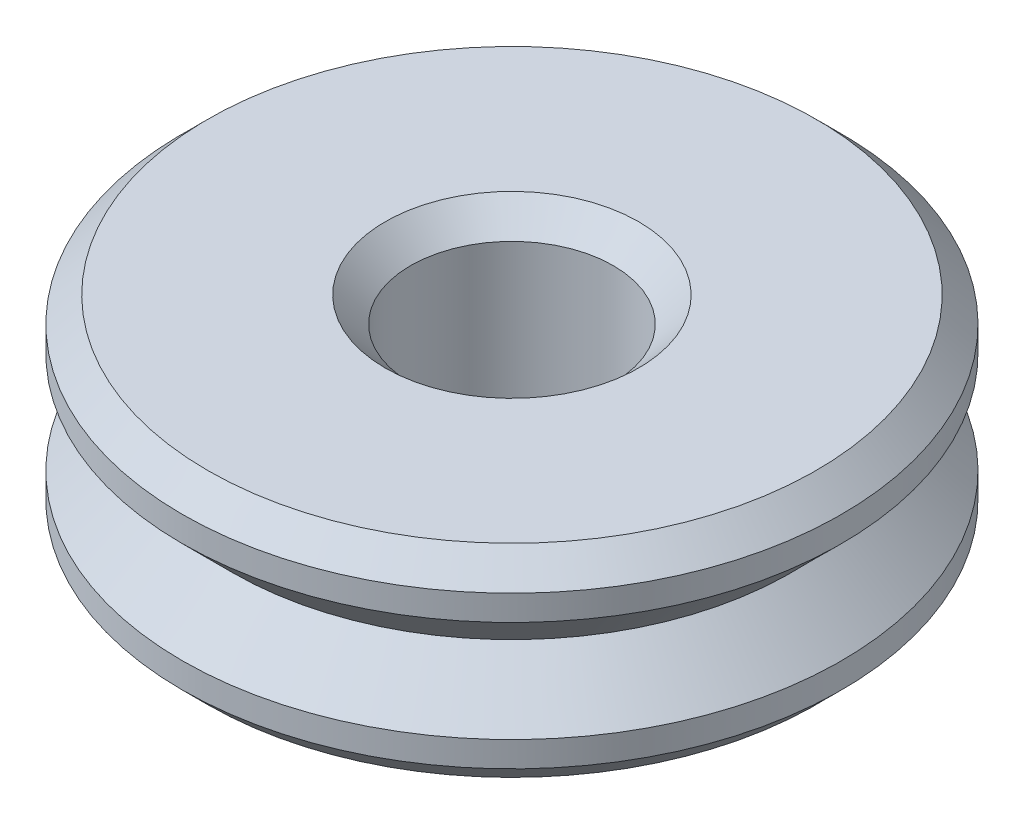
from build123d import *

# Parameters (mm, degrees)
SKETCH1_R           = 6.5
SKETCH1_R_2         = 2
BOSS_EXTRUDE1_DEPTH = 4
CHAMFER1_SIZE       = 0.5


with BuildPart() as part:
    # Sketch1 → Boss-Extrude1 (new body)
    with BuildSketch(Plane(origin=(0, 0, 0), x_dir=(1, 0, 0), z_dir=(0, 1, 0))):
        Circle(SKETCH1_R)
        Circle(SKETCH1_R_2, mode=Mode.SUBTRACT)
    extrude(amount=BOSS_EXTRUDE1_DEPTH)

    # Sketch2 → Cut-Revolve1 (revolve, cut)
    with BuildSketch(Plane(origin=(0, 0, 0), x_dir=(0, 0, -1), z_dir=(1, 0, 0))):
        Polygon((-6.5, 3), (-6.5, 1), (-5.5, 2), align=None)
    revolve(axis=Axis((0, 4, 0), (0, -1, 0)), mode=Mode.SUBTRACT)

    # Chamfer1
    chamfer1_edges = [part.edges().sort_by_distance(p)[0] for p in [
        (-6.5, 0, 0),
        (-6.5, 4, 0),
        (-2, 0, 0),
        (-2, 4, 0),
    ]]
    chamfer(chamfer1_edges, length=CHAMFER1_SIZE)


solid = part.part
